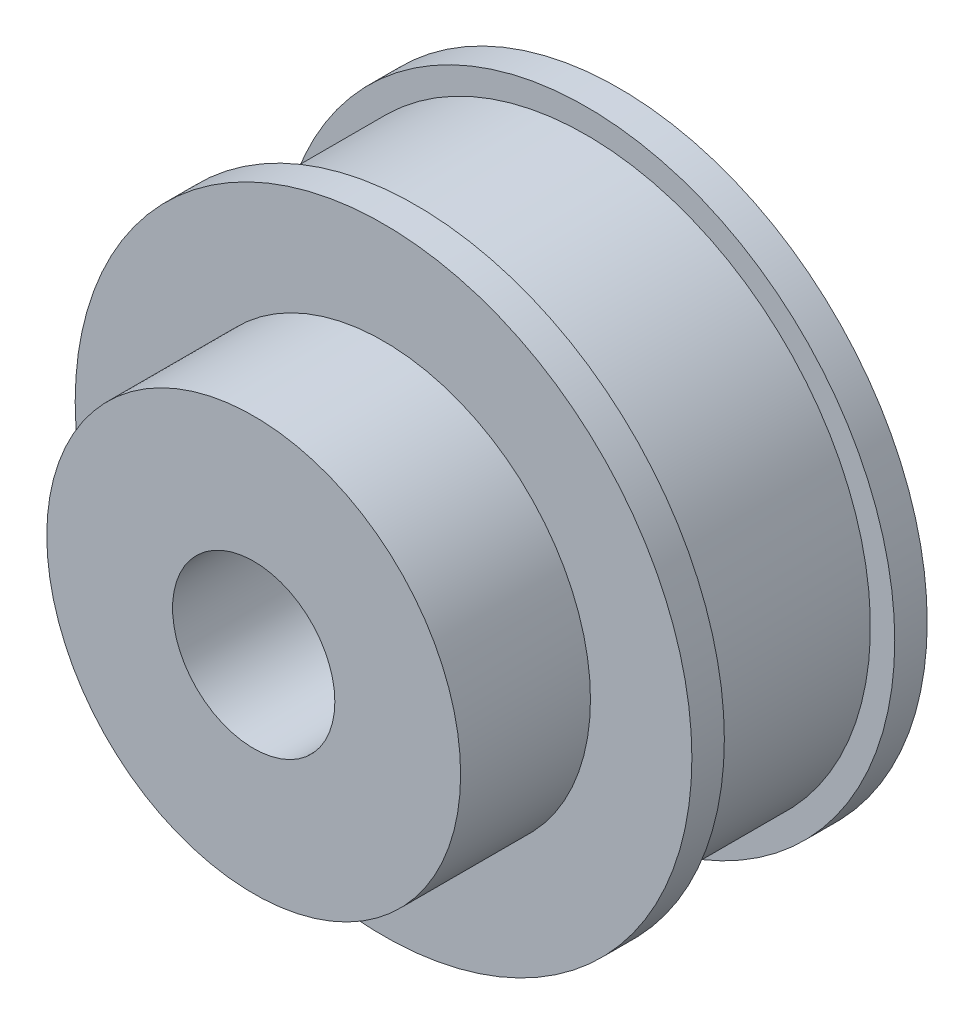
from build123d import *

# Parameters (mm, degrees)
SKETCH1_R           = 17.5
SKETCH1_R_2         = 5
BOSS_EXTRUDE1_DEPTH = 14.5
SKETCH2_R           = 12.75
SKETCH2_R_2         = 5
BOSS_EXTRUDE2_DEPTH = 8
SKETCH3_R           = 19
SKETCH3_R_2         = 17.5
BOSS_EXTRUDE3_DEPTH = 2
BOSS_EXTRUDE5_START = -14.5
SKETCH3_2_R         = 19
SKETCH3_2_R_2       = 17.5
BOSS_EXTRUDE5_DEPTH = 2


with BuildPart() as part:
    # Sketch1 → Boss-Extrude1 (new body)
    with BuildSketch(Plane.XY):
        Circle(SKETCH1_R)
        Circle(SKETCH1_R_2, mode=Mode.SUBTRACT)
    extrude(amount=BOSS_EXTRUDE1_DEPTH)

    # Sketch2 → Boss-Extrude2 (add)
    with BuildSketch(Plane.XY.offset(14.5)):
        Circle(SKETCH2_R)
        Circle(SKETCH2_R_2, mode=Mode.SUBTRACT)
    extrude(amount=BOSS_EXTRUDE2_DEPTH)

    # Sketch3 → Boss-Extrude3 (add)
    with BuildSketch(Plane(origin=(0, 0, 0), x_dir=(-1, 0, 0), z_dir=(0, 0, -1))):
        Circle(SKETCH3_R)
        Circle(SKETCH3_R_2, mode=Mode.SUBTRACT)
    extrude(amount=-BOSS_EXTRUDE3_DEPTH)

    # Sketch3_2 → Boss-Extrude5 (add)
    with BuildSketch(Plane(origin=(0, 0, 0), x_dir=(-1, 0, 0), z_dir=(0, 0, -1)).offset(BOSS_EXTRUDE5_START)):
        Circle(SKETCH3_2_R)
        Circle(SKETCH3_2_R_2, mode=Mode.SUBTRACT)
    extrude(amount=BOSS_EXTRUDE5_DEPTH)


solid = part.part
